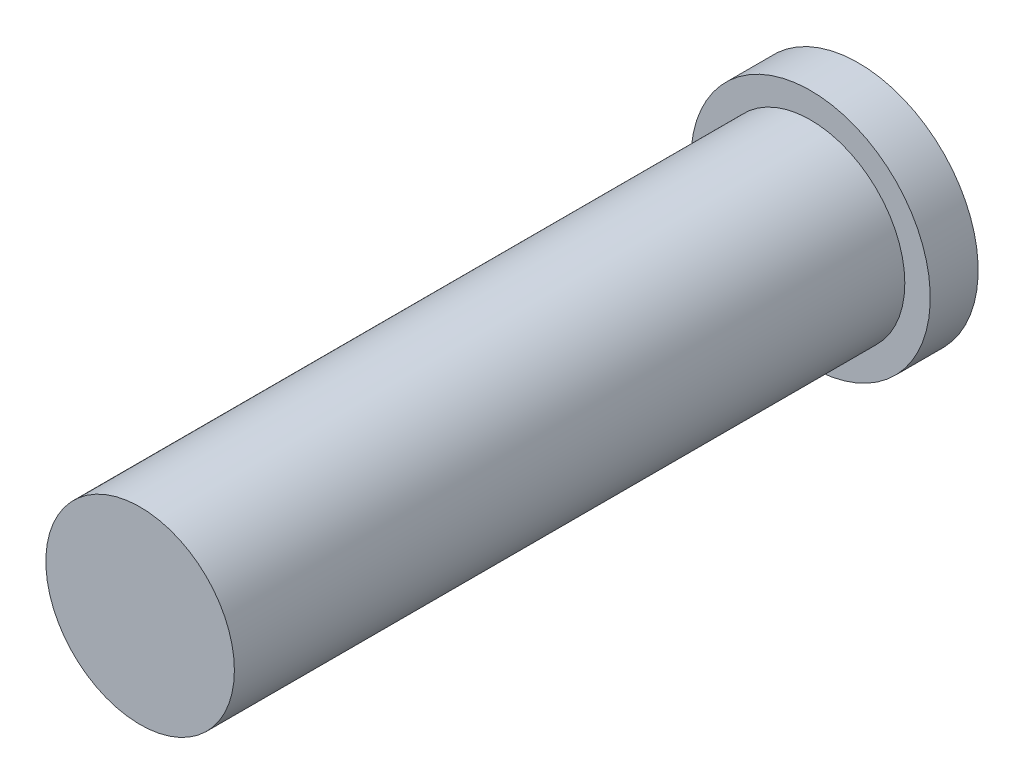
from build123d import *

# Parameters (mm, degrees)
SKETCH2_R               = 5
BOSS_EXTRUDE1_DEPTH     = 35.56
CUT_EXTRUDE1_DEPTH      = 25.4
CUT_EXTRUDE1_DEPTH_BACK = 1
SKETCH3_R               = 6.35
BOSS_EXTRUDE2_DEPTH     = 2.54
CUT_EXTRUDE2_DEPTH      = 2.54
SKETCH5_R               = 2.5
CUT_EXTRUDE3_DEPTH      = 28.575


with BuildPart() as part:
    # Sketch2 → Boss-Extrude1 (new body)
    with BuildSketch(Plane.XY):
        with Locations((13.074576669, 1.623038211)):
            Circle(SKETCH2_R)
    extrude(amount=BOSS_EXTRUDE1_DEPTH)

    # Sketch1 → Cut-Extrude1 (cut, two sides)
    with BuildSketch(Plane.XY) as cut_extrude1_sk:
        with BuildLine():
            Line((15.515382974, 2.163838155), (14.277170381, -0.568711858))
            ThreePointArc((14.277170381, -0.568711858), (10.797451658, 2.654882038), (15.515382974, 2.163838155))
        make_face()
    extrude(amount=CUT_EXTRUDE1_DEPTH, mode=Mode.SUBTRACT)
    extrude(cut_extrude1_sk.sketch, amount=-CUT_EXTRUDE1_DEPTH_BACK, mode=Mode.SUBTRACT)

    # Sketch3 → Boss-Extrude2 (add)
    with BuildSketch(Plane(origin=(0, 0, 0), x_dir=(-1, 0, 0), z_dir=(0, 0, -1))):
        with Locations((-13.074576669, 1.623038211)):
            Circle(SKETCH3_R)
    extrude(amount=BOSS_EXTRUDE2_DEPTH)

    # Sketch4 → Cut-Extrude2 (cut)
    with BuildSketch(Plane(origin=(0, 0, -2.54), x_dir=(-1, 0, 0), z_dir=(0, 0, -1))):
        with BuildLine():
            Line((-15.515382974, 2.163838155), (-14.277170381, -0.568711858))
            ThreePointArc((-14.277170381, -0.568711858), (-10.797451658, 2.654882038), (-15.515382974, 2.163838155))
        make_face()
    extrude(amount=-CUT_EXTRUDE2_DEPTH, mode=Mode.SUBTRACT)

    # Sketch5 → Cut-Extrude3 (cut)
    with BuildSketch(Plane(origin=(0, 0, -2.54), x_dir=(-1, 0, 0), z_dir=(0, 0, -1))):
        with Locations((-13.074576669, 1.623038211)):
            Circle(SKETCH5_R)
    extrude(amount=-CUT_EXTRUDE3_DEPTH, mode=Mode.SUBTRACT)


solid = part.part
